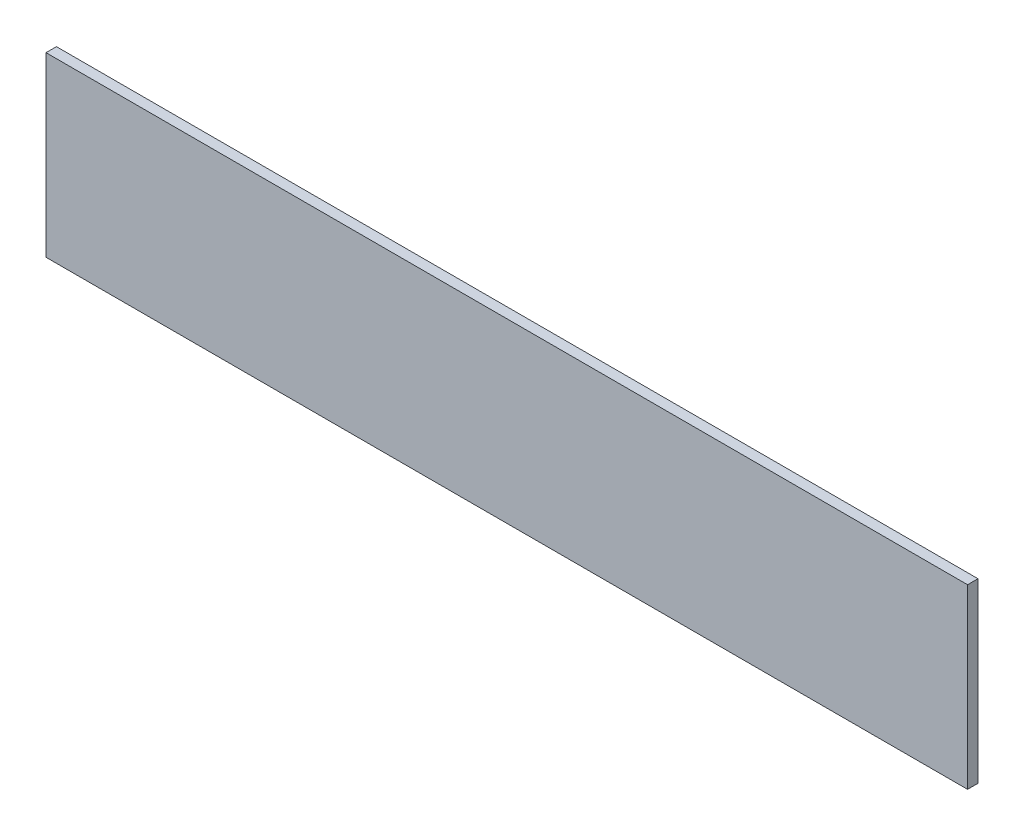
from build123d import *

# Parameters (mm, degrees)
SKETCH1_W           = 88.4
SKETCH1_H           = 17
BOSS_EXTRUDE1_DEPTH = 1


with BuildPart() as part:
    # Sketch1 → Boss-Extrude1 (new body)
    with BuildSketch(Plane.XY):
        with Locations((2.05547482, -11.135386556)):
            Rectangle(SKETCH1_W, SKETCH1_H)
    extrude(amount=BOSS_EXTRUDE1_DEPTH)


solid = part.part
